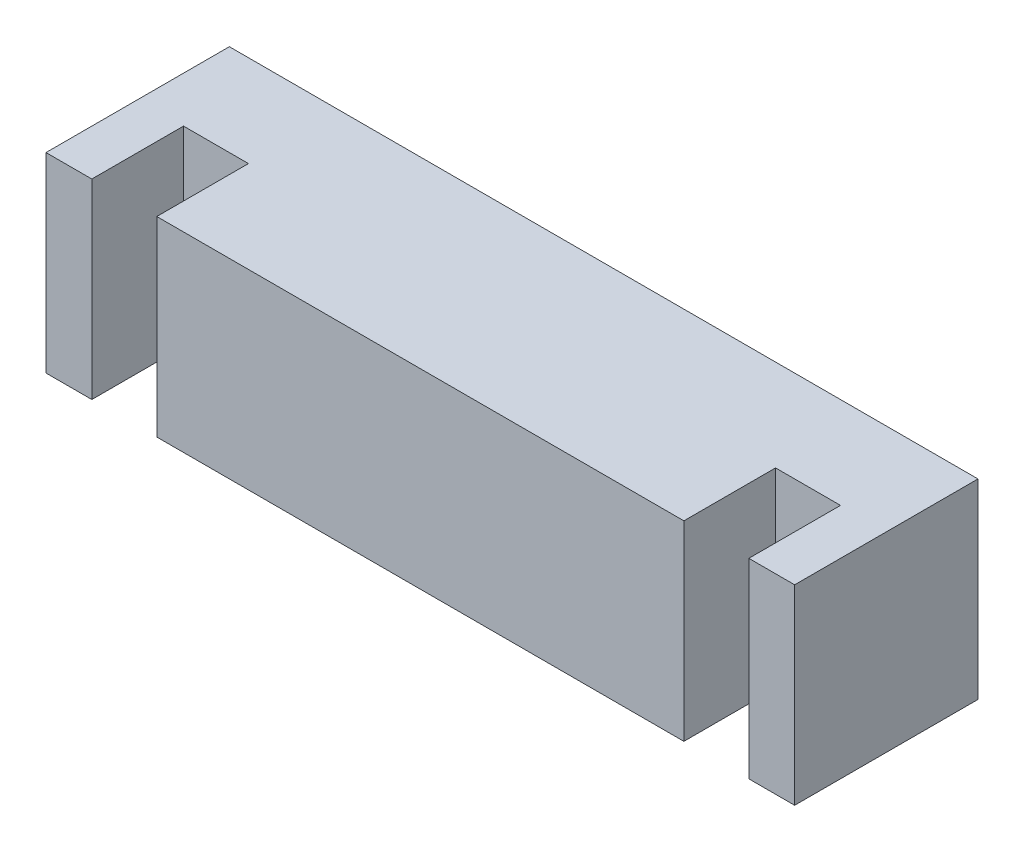
from build123d import *

# Parameters (mm, degrees)
SKETCH1_W           = 19.6
SKETCH1_H           = 5
BOSS_EXTRUDE1_DEPTH = 2.4
SKETCH2_W           = 1.2
SKETCH2_H           = 5
SKETCH2_W_2         = 13.8
BOSS_EXTRUDE2_DEPTH = 2.4


with BuildPart() as part:
    # Sketch1 → Boss-Extrude1 (new body)
    with BuildSketch(Plane.XY):
        with Locations((9.8, 2.5)):
            Rectangle(SKETCH1_W, SKETCH1_H)
    extrude(amount=BOSS_EXTRUDE1_DEPTH)

    # Sketch2 → Boss-Extrude2 (add)
    with BuildSketch(Plane.XY.offset(2.4)):
        with Locations((0.6, 2.5)):
            Rectangle(SKETCH2_W, SKETCH2_H)
        with Locations((19, 2.5)):
            Rectangle(SKETCH2_W, SKETCH2_H)
        with Locations((9.8, 2.5)):
            Rectangle(SKETCH2_W_2, SKETCH2_H)
    extrude(amount=BOSS_EXTRUDE2_DEPTH)


solid = part.part
